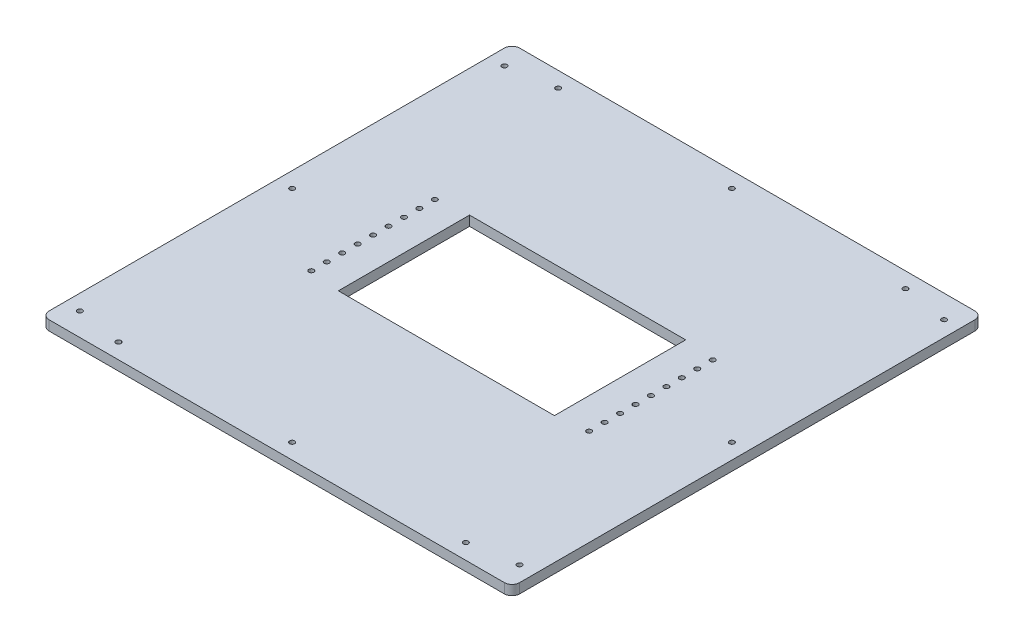
from build123d import *

# Parameters (mm, degrees)
SKETCH1_W                            = 609.6
SKETCH1_H                            = 609.6
LEXAN_BOSS_EXTRUDE1_DEPTH            = 12.7
HOUSING_NEST_HOLE_CUT_EXTRUDE1_REACH = 14.7
SKETCH5_W                            = 280
SKETCH5_H                            = 170
CUT_EXTRUDE7_REACH                   = 14.7
SKETCH6_R                            = 3.25
SKETCH9_R                            = 3.25
CUT_EXTRUDE6_DEPTH                   = 13.7
LPATTERN5_COUNT                      = 5
LPATTERN5_PITCH                      = 20
LPATTERN5_COL_COUNT                  = 5
LPATTERN5_COL_PITCH                  = 20
FILLET3_R                            = 10


with BuildPart() as part:
    # Sketch1 → Lexan Boss-Extrude1 (new body)
    with BuildSketch(Plane(origin=(0, 0, 0), x_dir=(1, 0, 0), z_dir=(0, 1, 0))):
        Rectangle(SKETCH1_W, SKETCH1_H)
    extrude(amount=LEXAN_BOSS_EXTRUDE1_DEPTH)

    # Sketch5 → Housing nest hole Cut-Extrude1 (cut, up to next)
    with BuildSketch(Plane.XZ, mode=Mode.PRIVATE) as housing_nest_hole_cut_extrude1_sk1:
        Rectangle(SKETCH5_W, SKETCH5_H)
    housing_nest_hole_cut_extrude1_tool1 = extrude(housing_nest_hole_cut_extrude1_sk1.sketch, amount=-HOUSING_NEST_HOLE_CUT_EXTRUDE1_REACH, mode=Mode.PRIVATE) & part.part
    add(housing_nest_hole_cut_extrude1_tool1.solids().sort_by_distance((0, 0, 0))[0], mode=Mode.SUBTRACT)

    # Sketch6 → Cut-Extrude7 (cut, up to next)
    with BuildSketch(Plane.XZ, mode=Mode.PRIVATE) as cut_extrude7_sk1:
        with Locations((-284.8, 275)):
            Circle(SKETCH6_R)
    cut_extrude7_tool1 = extrude(cut_extrude7_sk1.sketch, amount=-CUT_EXTRUDE7_REACH, mode=Mode.PRIVATE) & part.part
    add(cut_extrude7_tool1.solids().sort_by_distance((-284.8, 0, 275))[0], mode=Mode.SUBTRACT)
    # Sketch6 → Cut-Extrude7 (cut, up to next)
    with BuildSketch(Plane.XZ, mode=Mode.PRIVATE) as cut_extrude7_sk2:
        with Locations((-284.8, 0)):
            Circle(SKETCH6_R)
    cut_extrude7_tool2 = extrude(cut_extrude7_sk2.sketch, amount=-CUT_EXTRUDE7_REACH, mode=Mode.PRIVATE) & part.part
    add(cut_extrude7_tool2.solids().sort_by_distance((-284.8, 0, 0))[0], mode=Mode.SUBTRACT)
    # Sketch6 → Cut-Extrude7 (cut, up to next)
    with BuildSketch(Plane.XZ, mode=Mode.PRIVATE) as cut_extrude7_sk3:
        with Locations((-284.8, -275)):
            Circle(SKETCH6_R)
    cut_extrude7_tool3 = extrude(cut_extrude7_sk3.sketch, amount=-CUT_EXTRUDE7_REACH, mode=Mode.PRIVATE) & part.part
    add(cut_extrude7_tool3.solids().sort_by_distance((-284.8, 0, -275))[0], mode=Mode.SUBTRACT)
    # Sketch6 → Cut-Extrude7 (cut, up to next)
    with BuildSketch(Plane.XZ, mode=Mode.PRIVATE) as cut_extrude7_sk4:
        with Locations((284.8, -275)):
            Circle(SKETCH6_R)
    cut_extrude7_tool4 = extrude(cut_extrude7_sk4.sketch, amount=-CUT_EXTRUDE7_REACH, mode=Mode.PRIVATE) & part.part
    add(cut_extrude7_tool4.solids().sort_by_distance((284.8, 0, -275))[0], mode=Mode.SUBTRACT)
    # Sketch6 → Cut-Extrude7 (cut, up to next)
    with BuildSketch(Plane.XZ, mode=Mode.PRIVATE) as cut_extrude7_sk5:
        with Locations((284.8, 0)):
            Circle(SKETCH6_R)
    cut_extrude7_tool5 = extrude(cut_extrude7_sk5.sketch, amount=-CUT_EXTRUDE7_REACH, mode=Mode.PRIVATE) & part.part
    add(cut_extrude7_tool5.solids().sort_by_distance((284.8, 0, 0))[0], mode=Mode.SUBTRACT)
    # Sketch6 → Cut-Extrude7 (cut, up to next)
    with BuildSketch(Plane.XZ, mode=Mode.PRIVATE) as cut_extrude7_sk6:
        with Locations((284.8, 275)):
            Circle(SKETCH6_R)
    cut_extrude7_tool6 = extrude(cut_extrude7_sk6.sketch, amount=-CUT_EXTRUDE7_REACH, mode=Mode.PRIVATE) & part.part
    add(cut_extrude7_tool6.solids().sort_by_distance((284.8, 0, 275))[0], mode=Mode.SUBTRACT)
    # Sketch6 → Cut-Extrude7 (cut, up to next)
    with BuildSketch(Plane.XZ, mode=Mode.PRIVATE) as cut_extrude7_sk7:
        with Locations((-225, 284.8)):
            Circle(SKETCH6_R)
    cut_extrude7_tool7 = extrude(cut_extrude7_sk7.sketch, amount=-CUT_EXTRUDE7_REACH, mode=Mode.PRIVATE) & part.part
    add(cut_extrude7_tool7.solids().sort_by_distance((-225, 0, 284.8))[0], mode=Mode.SUBTRACT)
    # Sketch6 → Cut-Extrude7 (cut, up to next)
    with BuildSketch(Plane.XZ, mode=Mode.PRIVATE) as cut_extrude7_sk8:
        with Locations((0, 284.8)):
            Circle(SKETCH6_R)
    cut_extrude7_tool8 = extrude(cut_extrude7_sk8.sketch, amount=-CUT_EXTRUDE7_REACH, mode=Mode.PRIVATE) & part.part
    add(cut_extrude7_tool8.solids().sort_by_distance((0, 0, 284.8))[0], mode=Mode.SUBTRACT)
    # Sketch6 → Cut-Extrude7 (cut, up to next)
    with BuildSketch(Plane.XZ, mode=Mode.PRIVATE) as cut_extrude7_sk9:
        with Locations((225, 284.8)):
            Circle(SKETCH6_R)
    cut_extrude7_tool9 = extrude(cut_extrude7_sk9.sketch, amount=-CUT_EXTRUDE7_REACH, mode=Mode.PRIVATE) & part.part
    add(cut_extrude7_tool9.solids().sort_by_distance((225, 0, 284.8))[0], mode=Mode.SUBTRACT)
    # Sketch6 → Cut-Extrude7 (cut, up to next)
    with BuildSketch(Plane.XZ, mode=Mode.PRIVATE) as cut_extrude7_sk10:
        with Locations((225, -284.8)):
            Circle(SKETCH6_R)
    cut_extrude7_tool10 = extrude(cut_extrude7_sk10.sketch, amount=-CUT_EXTRUDE7_REACH, mode=Mode.PRIVATE) & part.part
    add(cut_extrude7_tool10.solids().sort_by_distance((225, 0, -284.8))[0], mode=Mode.SUBTRACT)
    # Sketch6 → Cut-Extrude7 (cut, up to next)
    with BuildSketch(Plane.XZ, mode=Mode.PRIVATE) as cut_extrude7_sk11:
        with Locations((0, -284.8)):
            Circle(SKETCH6_R)
    cut_extrude7_tool11 = extrude(cut_extrude7_sk11.sketch, amount=-CUT_EXTRUDE7_REACH, mode=Mode.PRIVATE) & part.part
    add(cut_extrude7_tool11.solids().sort_by_distance((0, 0, -284.8))[0], mode=Mode.SUBTRACT)
    # Sketch6 → Cut-Extrude7 (cut, up to next)
    with BuildSketch(Plane.XZ, mode=Mode.PRIVATE) as cut_extrude7_sk12:
        with Locations((-225, -284.8)):
            Circle(SKETCH6_R)
    cut_extrude7_tool12 = extrude(cut_extrude7_sk12.sketch, amount=-CUT_EXTRUDE7_REACH, mode=Mode.PRIVATE) & part.part
    add(cut_extrude7_tool12.solids().sort_by_distance((-225, 0, -284.8))[0], mode=Mode.SUBTRACT)

    # Sketch9 → Cut-Extrude6 (cut, through all)
    with BuildSketch(Plane(origin=(0, 12.7, 0), x_dir=(1, 0, 0), z_dir=(0, 1, 0))):
        with Locations((-180, 0)):
            Circle(SKETCH9_R)
        with Locations((180, 0)):
            Circle(SKETCH9_R)
    cut_extrude6 = extrude(amount=-CUT_EXTRUDE6_DEPTH, mode=Mode.SUBTRACT)

    # LPattern5: Cut-Extrude6 ×5
    with Locations(*[(0, 0, i * LPATTERN5_PITCH) for i in range(1, LPATTERN5_COUNT)]):
        add(cut_extrude6, mode=Mode.SUBTRACT)

    # LPattern5 col: Cut-Extrude6 ×5
    with Locations(*[(0, 0, -i * LPATTERN5_COL_PITCH) for i in range(1, LPATTERN5_COL_COUNT)]):
        add(cut_extrude6, mode=Mode.SUBTRACT)

    # Fillet3
    fillet3_edges = [part.edges().sort_by_distance(p)[0] for p in [
        (304.8, 6.35, 304.8),
        (-304.8, 6.35, 304.8),
        (-304.8, 6.35, -304.8),
        (304.8, 6.35, -304.8),
    ]]
    fillet(fillet3_edges, radius=FILLET3_R)


solid = part.part
